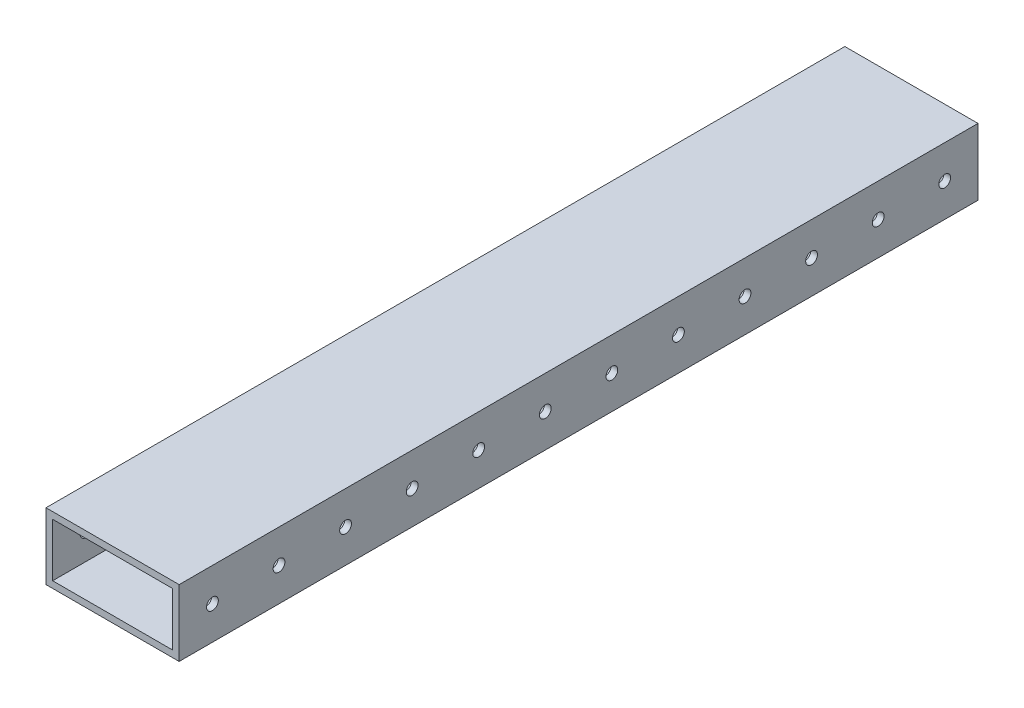
from build123d import *

# Parameters (mm, degrees)
SKETCH1_W             = 50.8
SKETCH1_H             = 25.4
SKETCH1_W_2           = 45.72
SKETCH1_H_2           = 20.32
BOSS_EXTRUDE1_DEPTH   = 533.4
F_8_CLEARANCE_HOLE1_D = 4.4958
CUT_EXTRUDE2_DEPTH    = 76.962


with BuildPart() as part:
    # Sketch1 → Boss-Extrude1 (new body)
    with BuildSketch(Plane.XY):
        Rectangle(SKETCH1_W, SKETCH1_H)
        Rectangle(SKETCH1_W_2, SKETCH1_H_2, mode=Mode.SUBTRACT)
    extrude(amount=-BOSS_EXTRUDE1_DEPTH)

    # #8 Clearance Hole1 (through all)
    with Locations(Plane(origin=(25.4, 0, 0), x_dir=(0, 0, -1), z_dir=(1, 0, 0))):
        with Locations((12.7, 0), (38.1, 0), (63.5, 0), (88.9, 0), (114.3, 0), (139.7, 0), (165.1, 0), (190.5, 0), (215.9, 0), (241.3, 0), (266.7, 0), (292.1, 0), (317.5, 0), (342.9, 0), (368.3, 0), (393.7, 0), (419.1, 0), (444.5, 0), (469.9, 0), (495.3, 0), (520.7, 0)):
            Hole(F_8_CLEARANCE_HOLE1_D / 2)

    # Sketch4 → Cut-Extrude2 (cut)
    with BuildSketch(Plane(origin=(0, 12.7, 0), x_dir=(1, 0, 0), z_dir=(0, 1, 0))):
        Polygon((-7.206301081, 228.6), (135.513081356, 228.6), (135.513081356, -17.641370014), (-94.056886123, -17.641370014), (-94.056886123, 228.6), align=None)
    extrude(amount=-CUT_EXTRUDE2_DEPTH, mode=Mode.SUBTRACT)


solid = part.part
